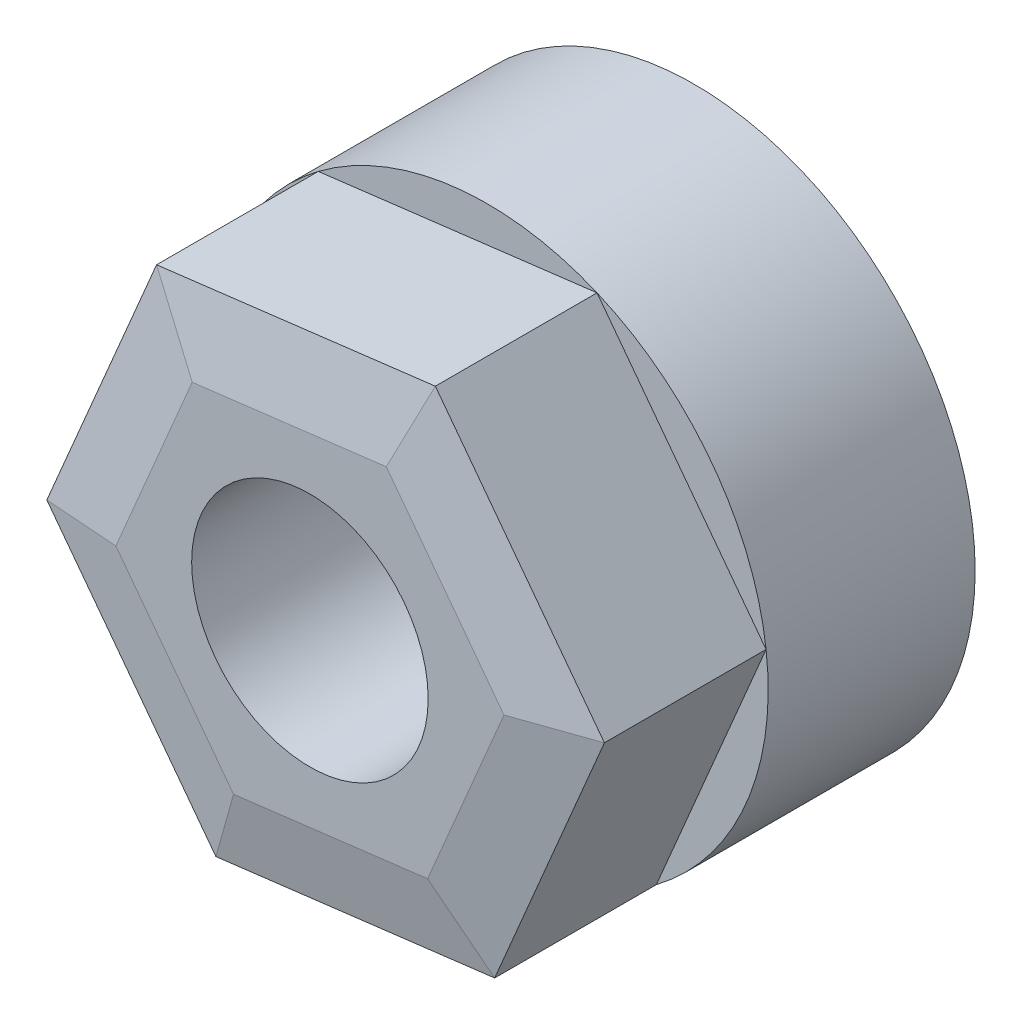
from build123d import *

# Parameters (mm, degrees)
CROQUIS1_R              = 9.5
SALIENTE_EXTRUIR1_DEPTH = 7
SALIENTE_EXTRUIR2_DEPTH = 6
CROQUIS3_R              = 4
CORTAR_EXTRUIR1_DEPTH   = 14
CHAFL_N1_SIZE           = 2.5
CHAFL_N1_SIZE2          = 0.531391404


with BuildPart() as part:
    # Croquis1 → Saliente-Extruir1 (new body)
    with BuildSketch(Plane.XY):
        Circle(CROQUIS1_R)
    extrude(amount=SALIENTE_EXTRUIR1_DEPTH)

    # Croquis2 → Saliente-Extruir2 (add)
    with BuildSketch(Plane.XY.offset(7)):
        Polygon((3.711506212, 8.744982655), (-5.717624029, 7.586749994), (-9.429130241, -1.158232661), (-3.711506212, -8.744982655), (5.717624029, -7.586749994), (9.429130241, 1.158232661), align=None)
    extrude(amount=SALIENTE_EXTRUIR2_DEPTH)

    # Croquis3 → Cortar-Extruir1 (cut, through all)
    with BuildSketch(Plane.XY.offset(13)):
        Circle(CROQUIS3_R)
    extrude(amount=-CORTAR_EXTRUIR1_DEPTH, mode=Mode.SUBTRACT)

    # Chaflán1
    chafl_n1_edges = [part.edges().sort_by_distance(p)[0] for p in [
        (6.570318227, 4.951607658, 13),
        (-1.003058908, 8.165866324, 13),
        (-7.573377135, 3.214258666, 13),
        (-6.570318227, -4.951607658, 13),
        (1.003058908, -8.165866324, 13),
        (7.573377135, -3.214258666, 13),
    ]]
    chafl_n1_side = [part.faces().sort_by_distance(p)[0] for p in [
        (-0.97170094, 7.910582237, 13),
    ]]
    chamfer(chafl_n1_edges, length=CHAFL_N1_SIZE, length2=CHAFL_N1_SIZE2, reference=chafl_n1_side[0])


solid = part.part
